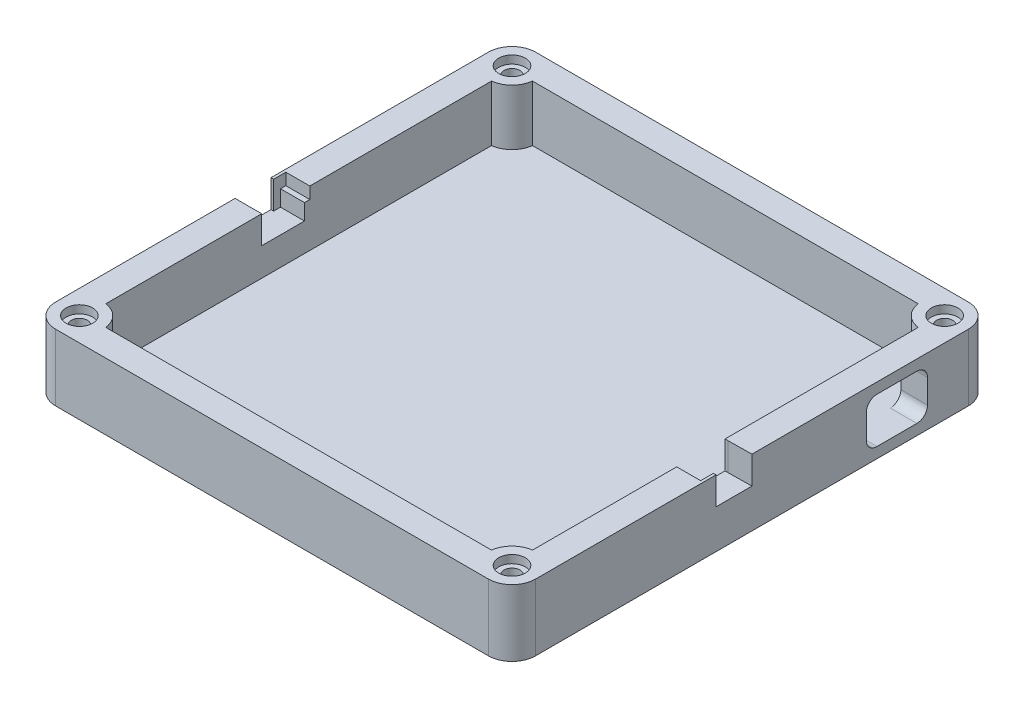
from build123d import *

# Parameters (mm, degrees)
SKETCH1_W           = 7.937979337
SKETCH1_H           = 0.559115352
BOSS_EXTRUDE1_DEPTH = 11.5
SKETCH2_R           = 1.5
CUT_EXTRUDE1_DEPTH  = 8
CUT_EXTRUDE2_DEPTH  = 8
SKETCH4_R           = 2.5
CUT_EXTRUDE3_DEPTH  = 1.5
BOSS_EXTRUDE2_DEPTH = 1
BOSS_EXTRUDE3_DEPTH = 1
SKETCH7_R           = 2.75
CUT_EXTRUDE4_DEPTH  = 1
SKETCH8_W           = 0.559115352
SKETCH8_H           = 2.28
SKETCH8_H_2         = 2.4
CUT_EXTRUDE5_DEPTH  = 5.2
SKETCH9_W           = 4.5
SKETCH9_H           = 1
BOSS_EXTRUDE4_DEPTH = 3


with BuildPart() as part:
    # Sketch1 → Boss-Extrude1 (new body)
    with BuildSketch(Plane(origin=(0, 0, 0), x_dir=(1, 0, 0), z_dir=(0, 1, 0))):
        with BuildLine():
            Line((-40.080884648, -36.23445276), (-40.080884648, 18.423402639))
            Line((-40.080884648, 18.423402639), (-40.64, 18.423402639))
            Line((-40.64, 18.423402639), (-40.64, -36.199115352))
            ThreePointArc((-40.64, -36.199115352), (-40.359884529, -36.207958509), (-40.080884648, -36.23445276))
        make_face()
        with BuildLine():
            Line((-40.080884648, 18.423402639), (-40.080884648, 36.23445276))
            ThreePointArc((-40.080884648, 36.23445276), (-40.359884529, 36.207958509), (-40.64, 36.199115352))
            Line((-40.64, 36.199115352), (-40.64, 18.423402639))
            Line((-40.64, 18.423402639), (-40.080884648, 18.423402639))
        make_face()
        with BuildLine():
            Line((-36.23445276, 40.080884648), (-7.937979337, 40.080884648))
            Line((-7.937979337, 40.080884648), (-7.937979337, 40.64))
            Line((-7.937979337, 40.64), (-36.199115352, 40.64))
            ThreePointArc((-36.199115352, 40.64), (-36.207958509, 40.359884529), (-36.23445276, 40.080884648))
        make_face()
        with BuildLine():
            Line((0, 40.64), (0, 40.080884648))
            Line((0, 40.080884648), (36.23445276, 40.080884648))
            ThreePointArc((36.23445276, 40.080884648), (36.207958509, 40.359884529), (36.199115352, 40.64))
            Line((36.199115352, 40.64), (0, 40.64))
        make_face()
        with Locations((-3.968989669, 40.360442324)):
            Rectangle(SKETCH1_W, SKETCH1_H)
        with BuildLine():
            ThreePointArc((40.64, 36.199115352), (40.359884529, 36.207958509), (40.080884648, 36.23445276))
            Line((40.080884648, 36.23445276), (40.080884648, 28.268480093))
            Line((40.080884648, 28.268480093), (40.64, 28.268480093))
            Line((40.64, 28.268480093), (40.64, 36.199115352))
        make_face()
        with BuildLine():
            Line((40.64, 28.268480093), (40.080884648, 28.268480093))
            Line((40.080884648, 28.268480093), (40.080884648, -36.23445276))
            ThreePointArc((40.080884648, -36.23445276), (40.359884529, -36.207958509), (40.64, -36.199115352))
            Line((40.64, -36.199115352), (40.64, 28.268480093))
        make_face()
        with BuildLine():
            ThreePointArc((40.64, -36.199115352), (40.359884529, -36.207958509), (40.080884648, -36.23445276))
            ThreePointArc((40.080884648, -36.23445276), (37.499820351, -37.499820351), (36.23445276, -40.080884648))
            ThreePointArc((36.23445276, -40.080884648), (36.207958509, -40.359884529), (36.199115352, -40.64))
            Line((36.199115352, -40.64), (40.64, -40.64))
            Line((40.64, -40.64), (40.64, -36.199115352))
        make_face()
        with BuildLine():
            ThreePointArc((45.080884648, -40.64), (43.780179649, -37.499820351), (40.64, -36.199115352))
            Line((40.64, -36.199115352), (40.64, -40.64))
            Line((40.64, -40.64), (36.199115352, -40.64))
            ThreePointArc((36.199115352, -40.64), (37.499820351, -43.780179649), (40.64, -45.080884648))
            ThreePointArc((40.64, -45.080884648), (43.780179649, -43.780179649), (45.080884648, -40.64))
        make_face()
        with BuildLine():
            ThreePointArc((36.199115352, -40.64), (36.207958509, -40.359884529), (36.23445276, -40.080884648))
            Line((36.23445276, -40.080884648), (27.085817246, -40.080884648))
            Line((27.085817246, -40.080884648), (27.085817246, -40.64))
            Line((27.085817246, -40.64), (36.199115352, -40.64))
        make_face()
        with BuildLine():
            Line((27.085817246, -40.080884648), (-36.23445276, -40.080884648))
            ThreePointArc((-36.23445276, -40.080884648), (-36.207958509, -40.359884529), (-36.199115352, -40.64))
            Line((-36.199115352, -40.64), (27.085817246, -40.64))
            Line((27.085817246, -40.64), (27.085817246, -40.080884648))
        make_face()
        with BuildLine():
            Line((-40.64, -40.64), (-40.64, -36.199115352))
            ThreePointArc((-40.64, -36.199115352), (-43.780179649, -37.499820351), (-45.080884648, -40.64))
            ThreePointArc((-45.080884648, -40.64), (-43.780179649, -43.780179649), (-40.64, -45.080884648))
            ThreePointArc((-40.64, -45.080884648), (-37.499820351, -43.780179649), (-36.199115352, -40.64))
            Line((-36.199115352, -40.64), (-40.64, -40.64))
        make_face()
        with BuildLine():
            ThreePointArc((-36.23445276, -40.080884648), (-37.499820351, -37.499820351), (-40.080884648, -36.23445276))
            ThreePointArc((-40.080884648, -36.23445276), (-40.359884529, -36.207958509), (-40.64, -36.199115352))
            Line((-40.64, -36.199115352), (-40.64, -40.64))
            Line((-40.64, -40.64), (-36.199115352, -40.64))
            ThreePointArc((-36.199115352, -40.64), (-36.207958509, -40.359884529), (-36.23445276, -40.080884648))
        make_face()
        with BuildLine():
            Line((-40.64, -40.64), (-40.64, -36.199115352))
            ThreePointArc((-40.64, -36.199115352), (-43.780179649, -37.499820351), (-45.080884648, -40.64))
            ThreePointArc((-45.080884648, -40.64), (-43.780179649, -43.780179649), (-40.64, -45.080884648))
            ThreePointArc((-40.64, -45.080884648), (-37.499820351, -43.780179649), (-36.199115352, -40.64))
            Line((-36.199115352, -40.64), (-40.64, -40.64))
        make_face()
        with BuildLine():
            Line((27.085817246, -40.64), (-36.199115352, -40.64))
            ThreePointArc((-36.199115352, -40.64), (-37.499820351, -43.780179649), (-40.64, -45.080884648))
            Line((-40.64, -45.080884648), (27.085817246, -45.080884648))
            Line((27.085817246, -45.080884648), (27.085817246, -40.64))
        make_face()
        with BuildLine():
            Line((-40.64, -36.199115352), (-40.64, 18.423402639))
            Line((-40.64, 18.423402639), (-45.080884648, 18.423402639))
            Line((-45.080884648, 18.423402639), (-45.080884648, -40.64))
            ThreePointArc((-45.080884648, -40.64), (-43.780179649, -37.499820351), (-40.64, -36.199115352))
        make_face()
        with BuildLine():
            ThreePointArc((45.080884648, -40.64), (43.780179649, -37.499820351), (40.64, -36.199115352))
            Line((40.64, -36.199115352), (40.64, -40.64))
            Line((40.64, -40.64), (36.199115352, -40.64))
            ThreePointArc((36.199115352, -40.64), (37.499820351, -43.780179649), (40.64, -45.080884648))
            ThreePointArc((40.64, -45.080884648), (43.780179649, -43.780179649), (45.080884648, -40.64))
        make_face()
        with BuildLine():
            ThreePointArc((40.64, -45.080884648), (37.499820351, -43.780179649), (36.199115352, -40.64))
            Line((36.199115352, -40.64), (27.085817246, -40.64))
            Line((27.085817246, -40.64), (27.085817246, -45.080884648))
            Line((27.085817246, -45.080884648), (40.64, -45.080884648))
        make_face()
        with BuildLine():
            Line((45.080884648, 28.268480093), (40.64, 28.268480093))
            Line((40.64, 28.268480093), (40.64, -36.199115352))
            ThreePointArc((40.64, -36.199115352), (43.780179649, -37.499820351), (45.080884648, -40.64))
            Line((45.080884648, -40.64), (45.080884648, 28.268480093))
        make_face()
        with BuildLine():
            ThreePointArc((45.080884648, 40.64), (43.780179649, 37.499820351), (40.64, 36.199115352))
            Line((40.64, 36.199115352), (40.64, 28.268480093))
            Line((40.64, 28.268480093), (45.080884648, 28.268480093))
            Line((45.080884648, 28.268480093), (45.080884648, 40.64))
        make_face()
        with BuildLine():
            ThreePointArc((40.64, 45.080884648), (37.499820351, 43.780179649), (36.199115352, 40.64))
            Line((36.199115352, 40.64), (40.64, 40.64))
            Line((40.64, 40.64), (40.64, 36.199115352))
            ThreePointArc((40.64, 36.199115352), (43.780179649, 37.499820351), (45.080884648, 40.64))
            ThreePointArc((45.080884648, 40.64), (43.780179649, 43.780179649), (40.64, 45.080884648))
        make_face()
        with BuildLine():
            ThreePointArc((36.199115352, 40.64), (36.207958509, 40.359884529), (36.23445276, 40.080884648))
            ThreePointArc((36.23445276, 40.080884648), (37.499820351, 37.499820351), (40.080884648, 36.23445276))
            ThreePointArc((40.080884648, 36.23445276), (40.359884529, 36.207958509), (40.64, 36.199115352))
            Line((40.64, 36.199115352), (40.64, 40.64))
            Line((40.64, 40.64), (36.199115352, 40.64))
        make_face()
        with BuildLine():
            ThreePointArc((40.64, 45.080884648), (37.499820351, 43.780179649), (36.199115352, 40.64))
            Line((36.199115352, 40.64), (40.64, 40.64))
            Line((40.64, 40.64), (40.64, 36.199115352))
            ThreePointArc((40.64, 36.199115352), (43.780179649, 37.499820351), (45.080884648, 40.64))
            ThreePointArc((45.080884648, 40.64), (43.780179649, 43.780179649), (40.64, 45.080884648))
        make_face()
        with BuildLine():
            Line((-7.937979337, 40.64), (0, 40.64))
            Line((0, 40.64), (36.199115352, 40.64))
            ThreePointArc((36.199115352, 40.64), (37.499820351, 43.780179649), (40.64, 45.080884648))
            Line((40.64, 45.080884648), (-7.937979337, 45.080884648))
            Line((-7.937979337, 45.080884648), (-7.937979337, 40.64))
        make_face()
        with BuildLine():
            Line((-36.199115352, 40.64), (-7.937979337, 40.64))
            Line((-7.937979337, 40.64), (-7.937979337, 45.080884648))
            Line((-7.937979337, 45.080884648), (-40.64, 45.080884648))
            ThreePointArc((-40.64, 45.080884648), (-37.499820351, 43.780179649), (-36.199115352, 40.64))
        make_face()
        with BuildLine():
            Line((-40.64, 40.64), (-36.199115352, 40.64))
            ThreePointArc((-36.199115352, 40.64), (-37.499820351, 43.780179649), (-40.64, 45.080884648))
            ThreePointArc((-40.64, 45.080884648), (-43.780179649, 43.780179649), (-45.080884648, 40.64))
            ThreePointArc((-45.080884648, 40.64), (-43.780179649, 37.499820351), (-40.64, 36.199115352))
            Line((-40.64, 36.199115352), (-40.64, 40.64))
        make_face()
        with BuildLine():
            ThreePointArc((-40.080884648, 36.23445276), (-37.499820351, 37.499820351), (-36.23445276, 40.080884648))
            ThreePointArc((-36.23445276, 40.080884648), (-36.207958509, 40.359884529), (-36.199115352, 40.64))
            Line((-36.199115352, 40.64), (-40.64, 40.64))
            Line((-40.64, 40.64), (-40.64, 36.199115352))
            ThreePointArc((-40.64, 36.199115352), (-40.359884529, 36.207958509), (-40.080884648, 36.23445276))
        make_face()
        with BuildLine():
            Line((-40.64, 40.64), (-36.199115352, 40.64))
            ThreePointArc((-36.199115352, 40.64), (-37.499820351, 43.780179649), (-40.64, 45.080884648))
            ThreePointArc((-40.64, 45.080884648), (-43.780179649, 43.780179649), (-45.080884648, 40.64))
            ThreePointArc((-45.080884648, 40.64), (-43.780179649, 37.499820351), (-40.64, 36.199115352))
            Line((-40.64, 36.199115352), (-40.64, 40.64))
        make_face()
        with BuildLine():
            Line((-40.64, 18.423402639), (-40.64, 36.199115352))
            ThreePointArc((-40.64, 36.199115352), (-43.780179649, 37.499820351), (-45.080884648, 40.64))
            Line((-45.080884648, 40.64), (-45.080884648, 18.423402639))
            Line((-45.080884648, 18.423402639), (-40.64, 18.423402639))
        make_face()
    extrude(amount=BOSS_EXTRUDE1_DEPTH)

    # Sketch2 → Cut-Extrude1 (cut)
    with BuildSketch(Plane(origin=(0, 11.5, 0), x_dir=(1, 0, 0), z_dir=(0, 1, 0))):
        with Locations((-40.64, 40.64)):
            Circle(SKETCH2_R)
        with Locations((40.64, 40.64)):
            Circle(SKETCH2_R)
        with Locations((40.64, -40.64)):
            Circle(SKETCH2_R)
        with Locations((-40.64, -40.64)):
            Circle(SKETCH2_R)
    extrude(amount=-CUT_EXTRUDE1_DEPTH, mode=Mode.SUBTRACT)

    # Sketch3 → Cut-Extrude2 (cut)
    with BuildSketch(Plane(origin=(45.080884648, 0, 0), x_dir=(0, 0, -1), z_dir=(1, 0, 0))):
        with BuildLine():
            Line((30.979, 9.5), (23.479, 9.5))
            ThreePointArc((23.479, 9.5), (22.064786438, 8.914213562), (21.479, 7.5))
            Line((21.479, 7.5), (21.479, 3))
            ThreePointArc((21.479, 3), (22.064786438, 1.585786438), (23.479, 1))
            Line((23.479, 1), (30.979, 1))
            ThreePointArc((30.979, 1), (32.393213562, 1.585786438), (32.979, 3))
            Line((32.979, 3), (32.979, 7.5))
            ThreePointArc((32.979, 7.5), (32.393213562, 8.914213562), (30.979, 9.5))
        make_face()
    extrude(amount=-CUT_EXTRUDE2_DEPTH, mode=Mode.SUBTRACT)

    # Sketch4 → Cut-Extrude3 (cut)
    with BuildSketch(Plane(origin=(0, 11.5, 0), x_dir=(1, 0, 0), z_dir=(0, 1, 0))):
        with Locations((-40.64, 40.64)):
            Circle(SKETCH4_R)
        with Locations((40.64, 40.64)):
            Circle(SKETCH4_R)
        with Locations((40.64, -40.64)):
            Circle(SKETCH4_R)
        with Locations((-40.64, -40.64)):
            Circle(SKETCH4_R)
    extrude(amount=-CUT_EXTRUDE3_DEPTH, mode=Mode.SUBTRACT)

    # Sketch5 → Boss-Extrude2 (add)
    with BuildSketch(Plane.XZ):
        with BuildLine():
            ThreePointArc((36.23445276, 40.080884648), (37.499820351, 37.499820351), (40.080884648, 36.23445276))
            Line((40.080884648, 36.23445276), (40.080884648, -36.23445276))
            ThreePointArc((40.080884648, -36.23445276), (37.499820351, -37.499820351), (36.23445276, -40.080884648))
            Line((36.23445276, -40.080884648), (-36.23445276, -40.080884648))
            ThreePointArc((-36.23445276, -40.080884648), (-37.499820351, -37.499820351), (-40.080884648, -36.23445276))
            Line((-40.080884648, -36.23445276), (-40.080884648, 36.23445276))
            ThreePointArc((-40.080884648, 36.23445276), (-37.499820351, 37.499820351), (-36.23445276, 40.080884648))
            Line((-36.23445276, 40.080884648), (36.23445276, 40.080884648))
        make_face()
    extrude(amount=-BOSS_EXTRUDE2_DEPTH)

    # Sketch6 → Boss-Extrude3 (add)
    with BuildSketch(Plane.XZ):
        with BuildLine():
            Line((40.64, 45.080884648), (-40.64, 45.080884648))
            ThreePointArc((-40.64, 45.080884648), (-43.780179649, 43.780179649), (-45.080884648, 40.64))
            Line((-45.080884648, 40.64), (-45.080884648, -40.64))
            ThreePointArc((-45.080884648, -40.64), (-43.780179649, -43.780179649), (-40.64, -45.080884648))
            Line((-40.64, -45.080884648), (40.64, -45.080884648))
            ThreePointArc((40.64, -45.080884648), (43.780179649, -43.780179649), (45.080884648, -40.64))
            Line((45.080884648, -40.64), (45.080884648, 40.64))
            ThreePointArc((45.080884648, 40.64), (43.780179649, 43.780179649), (40.64, 45.080884648))
        make_face()
    extrude(amount=BOSS_EXTRUDE3_DEPTH)

    # Sketch7 → Cut-Extrude4 (cut)
    with BuildSketch(Plane.XZ.offset(1)):
        with Locations((-40.64, 40.64)):
            Circle(SKETCH7_R)
        with Locations((40.64, 40.64)):
            Circle(SKETCH7_R)
        with Locations((40.64, -40.64)):
            Circle(SKETCH7_R)
        with Locations((-40.64, -40.64)):
            Circle(SKETCH7_R)
    extrude(amount=-CUT_EXTRUDE4_DEPTH, mode=Mode.SUBTRACT)

    # Sketch8 → Cut-Extrude5 (cut)
    with BuildSketch(Plane(origin=(0, 11.5, 0), x_dir=(1, 0, 0), z_dir=(0, 1, 0))):
        with Locations((-40.360442324, 0.95)):
            Rectangle(SKETCH8_W, SKETCH8_H)
        Polygon((-40.080884648, -0.19), (-40.64, -0.19), (-44.580884648, -0.19), (-45.080884648, -0.19), (-45.080884648, -6.94), (-40.64, -6.94), (-40.080884648, -6.94), align=None)
        Polygon((-44.580884648, -0.19), (-40.64, -0.19), (-40.64, 2.09), (-44.380884648, 2.09), (-44.580884648, 2.09), align=None)
        Polygon((40.080884648, -6.74), (40.64, -6.74), (44.580884648, -6.74), (45.080884648, -6.74), (45.080884648, 0), (40.64, -0.06), (40.080884648, -0.06), align=None)
        with Locations((40.360442324, -7.94)):
            Rectangle(SKETCH8_W, SKETCH8_H_2)
        Polygon((40.64, -6.74), (40.64, -9.14), (44.380884648, -9.14), (44.580884648, -9.14), (44.580884648, -6.74), align=None)
    extrude(amount=-CUT_EXTRUDE5_DEPTH, mode=Mode.SUBTRACT)

    # Sketch9 → Boss-Extrude4 (add)
    with BuildSketch(Plane(origin=(0, 6.3, 0), x_dir=(1, 0, 0), z_dir=(0, 1, 0))):
        with Locations((42.330884648, -8.64)):
            Rectangle(SKETCH9_W, SKETCH9_H)
        with Locations((-42.330884648, 1.59)):
            Rectangle(SKETCH9_W, SKETCH9_H)
    extrude(amount=BOSS_EXTRUDE4_DEPTH)


solid = part.part
